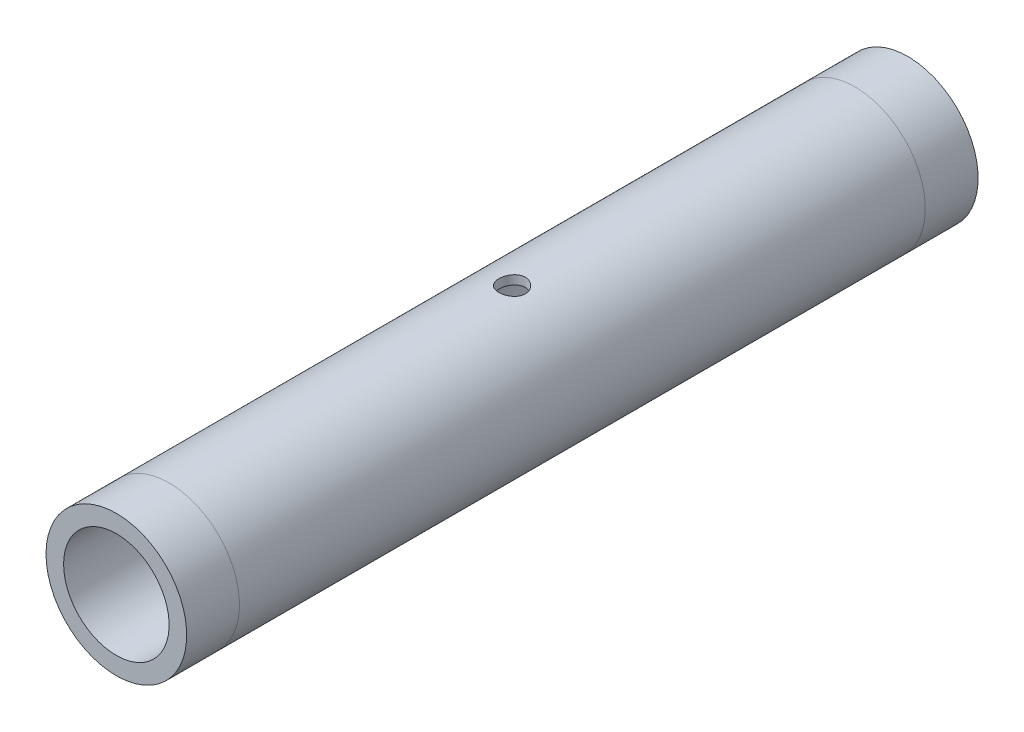
from build123d import *

# Parameters (mm, degrees)
SCHNITT_LINEAR_AUSTRAGEN1_DEPTH      = 24.200215516
SCHNITT_LINEAR_AUSTRAGEN1_DEPTH_BACK = 24.200215516
SKIZZE2_R                            = 0.75


with BuildPart() as part:
    # Skizze1 → Rotation1 (revolve)
    with BuildSketch(Plane(origin=(0, 0, 0), x_dir=(0, 0, -1), z_dir=(1, 0, 0))):
        Polygon((-19.5, 4), (-19.5, 3.5), (-16.5, 3.5), (16.5, 3.5), (19.5, 3.5), (19.5, 4), align=None)
    revolve(axis=Axis((0, 0, 0), (0, 0, 1)))

    # Skizze2 → Schnitt-Linear austragen1 (cut, two sides: drawn at the far end of the back side and taken through both)
    with BuildSketch(Plane(origin=(0, 0, 0), x_dir=(1, 0, 0), z_dir=(0, 1, 0)).offset(-SCHNITT_LINEAR_AUSTRAGEN1_DEPTH_BACK)):
        Circle(SKIZZE2_R)
    extrude(amount=SCHNITT_LINEAR_AUSTRAGEN1_DEPTH + SCHNITT_LINEAR_AUSTRAGEN1_DEPTH_BACK, mode=Mode.SUBTRACT)


with BuildPart() as body_2:
    # Skizze1_3 → Rotation3 (revolve)
    with BuildSketch(Plane(origin=(0, 0, 0), x_dir=(0, 0, -1), z_dir=(1, 0, 0))):
        Polygon((-16.5, 3.5), (-19.5, 3.5), (-19.5, 4), (-22.5, 4), (-22.5, 3), (-16.5, 3), align=None)
        Polygon((19.5, 3.5), (16.5, 3.5), (16.5, 3), (22.5, 3), (22.5, 4), (19.5, 4), align=None)
    revolve(axis=Axis((0, 0, 0), (0, 0, 1)))


solid = Compound([part.part, body_2.part])
